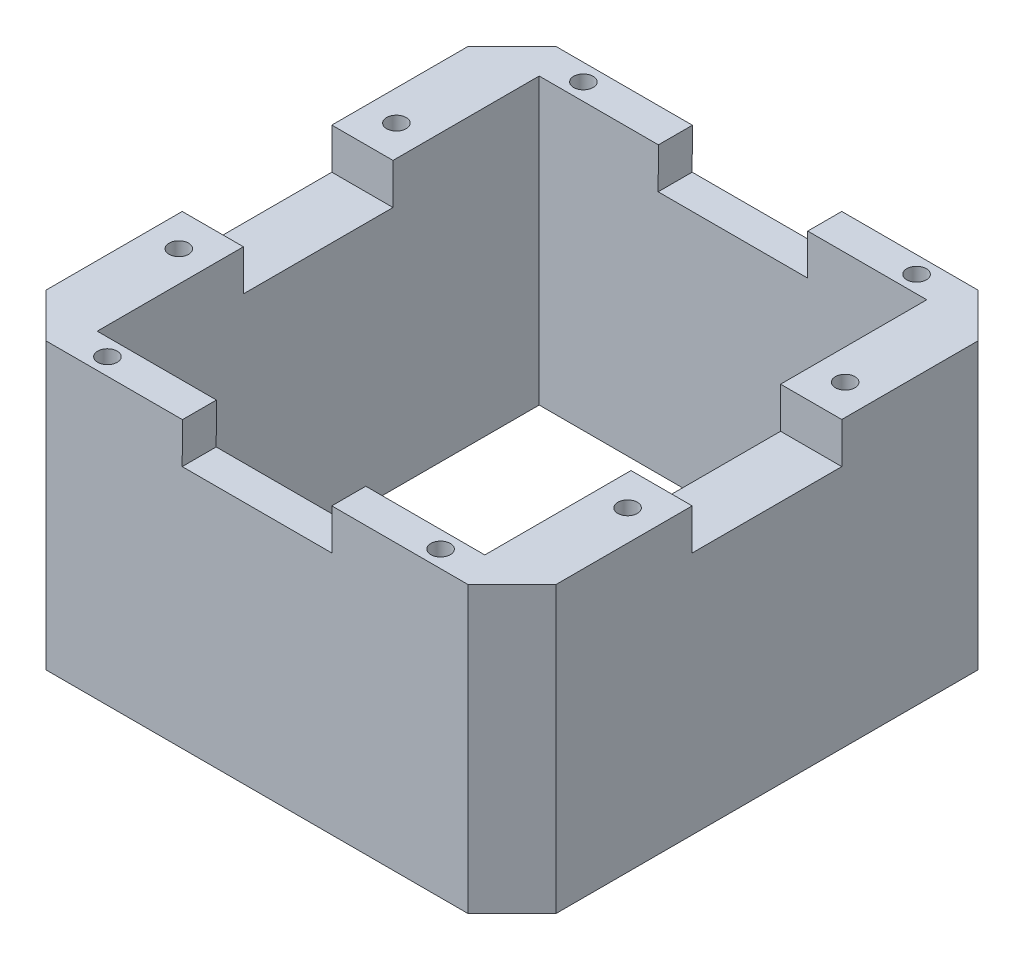
from build123d import *

# Parameters (mm, degrees)
SKETCH2_W                          = 75
SKETCH2_H                          = 75
SKETCH2_W_2                        = 57
SKETCH2_H_2                        = 65
BOSS_EXTRUDE1_DEPTH                = 41.91
CUT_EXTRUDE1_DEPTH                 = 92.91
SKETCH6_W                          = 22
SKETCH6_H                          = 6
CUT_EXTRUDE2_DEPTH                 = 92.91
CUT_EXTRUDE3_DEPTH                 = 92.91
CIRPATTERN1_COUNT                  = 4
TAP_DRILL_FOR_6_40_TAP1_AT_2_COUNT = 2
TAP_DRILL_FOR_6_40_TAP1_AT_2_PITCH = 32
CIRPATTERN2_COUNT                  = 2
TAP_DRILL_FOR_6_40_TAP2_AT_2_COUNT = 2
TAP_DRILL_FOR_6_40_TAP2_AT_2_PITCH = 49
CIRPATTERN4_COUNT                  = 2


with BuildPart() as part:
    # Sketch2 → Boss-Extrude1 (new body)
    with BuildSketch(Plane(origin=(0, 0, 0), x_dir=(1, 0, 0), z_dir=(0, 1, 0))):
        with Locations((-5.814990765, -18.037415397)):
            Rectangle(SKETCH2_W, SKETCH2_H)
        with Locations((-5.814990765, -18.037415397)):
            Rectangle(SKETCH2_W_2, SKETCH2_H_2, mode=Mode.SUBTRACT)
    extrude(amount=BOSS_EXTRUDE1_DEPTH)

    # Sketch4 → Cut-Extrude1 (cut)
    with BuildSketch(Plane(origin=(0, 0, -19.462584603), x_dir=(-1, 0, 0), z_dir=(0, 0, -1))):
        Polygon((16.782729205, 41.915021022), (-5.180449965, 41.91), (-5.180449965, 35.91), (16.819550035, 35.91), align=None)
    extrude(amount=-CUT_EXTRUDE1_DEPTH, mode=Mode.SUBTRACT)

    # Sketch6 → Cut-Extrude2 (cut)
    with BuildSketch(Plane.ZY.offset(43.314990765)):
        with Locations((18.037415397, 38.91)):
            Rectangle(SKETCH6_W, SKETCH6_H)
    extrude(amount=-CUT_EXTRUDE2_DEPTH, mode=Mode.SUBTRACT)

    # Sketch7 → Cut-Extrude3 (cut)
    with BuildSketch(Plane(origin=(0, 41.91, 0), x_dir=(1, 0, 0), z_dir=(0, 1, 0))):
        Polygon((31.685009235, 12.996800195), (25.219224828, 19.462584603), (31.685009235, 19.462584603), align=None)
    cut_extrude3 = extrude(amount=-CUT_EXTRUDE3_DEPTH, mode=Mode.SUBTRACT)

    # CirPattern1: Cut-Extrude3 ×4 about axis
    cirpattern1_axis = Axis((-5.814990765, 41.91, 18.037415397), (0, 1, 0))
    for i in range(1, CIRPATTERN1_COUNT):
        add(cut_extrude3.rotate(cirpattern1_axis, i * 360 / CIRPATTERN1_COUNT), mode=Mode.SUBTRACT)

    # Sketch18 → Tap Drill for _6-40 Tap1 (revolve, cut)
    with BuildSketch(Plane(origin=(-38.814990765, 41.91, 2.037415397), x_dir=(0, 0, 1), z_dir=(1, 0, 0))):
        Polygon((0, 0), (0, 20.862295074), (1.4351, 20), (1.4351, 0), align=None)
    tap_drill_for_6_40_tap1 = revolve(axis=Axis((-38.814990765, 48.26, 2.037415397), (0, -1, 0)), mode=Mode.SUBTRACT)

    # Tap Drill for _6-40 Tap1 at 2: Tap Drill for _6-40 Tap1 ×2
    with Locations(*[(0, 0, i * TAP_DRILL_FOR_6_40_TAP1_AT_2_PITCH) for i in range(1, TAP_DRILL_FOR_6_40_TAP1_AT_2_COUNT)]):
        add(tap_drill_for_6_40_tap1, mode=Mode.SUBTRACT)

    # CirPattern2: Tap Drill for _6-40 Tap1 ×2 about axis
    cirpattern2_axis = Axis((-5.814990765, 41.91, 18.037415397), (0, 1, 0))
    for i in range(1, CIRPATTERN2_COUNT):
        add(tap_drill_for_6_40_tap1.rotate(cirpattern2_axis, i * 360 / CIRPATTERN2_COUNT), mode=Mode.SUBTRACT)

    # CirPattern2 copy 1 sketch → CirPattern2 copy 1 (revolve, cut)
    with BuildSketch(Plane(origin=(27.185009235, 41.91, 2.037415397), x_dir=(0, 0, -1), z_dir=(-1, 0, 0))):
        Polygon((0, 0), (0, 20.862295074), (1.4351, 20), (1.4351, 0), align=None)
    revolve(axis=Axis((27.185009235, 48.26, 2.037415397), (0, -1, 0)), mode=Mode.SUBTRACT)

    # Sketch23 → Tap Drill for _6-40 Tap2 (revolve, cut)
    with BuildSketch(Plane(origin=(-30.314990765, 41.91, -16.962584603), x_dir=(0, 0, 1), z_dir=(1, 0, 0))):
        Polygon((0, 0), (0, 20.862295074), (1.4351, 20), (1.4351, 0), align=None)
    tap_drill_for_6_40_tap2 = revolve(axis=Axis((-30.314990765, 48.26, -16.962584603), (0, -1, 0)), mode=Mode.SUBTRACT)

    # Tap Drill for _6-40 Tap2 at 2: Tap Drill for _6-40 Tap2 ×2
    with Locations(*[(i * TAP_DRILL_FOR_6_40_TAP2_AT_2_PITCH, 0, 0) for i in range(1, TAP_DRILL_FOR_6_40_TAP2_AT_2_COUNT)]):
        add(tap_drill_for_6_40_tap2, mode=Mode.SUBTRACT)

    # CirPattern4: Tap Drill for _6-40 Tap2 ×2 about axis
    cirpattern4_axis = Axis((-5.814990765, 41.91, 18.037415397), (0, 1, 0))
    for i in range(1, CIRPATTERN4_COUNT):
        add(tap_drill_for_6_40_tap2.rotate(cirpattern4_axis, i * 360 / CIRPATTERN4_COUNT), mode=Mode.SUBTRACT)

    # CirPattern4 copy 1 sketch → CirPattern4 copy 1 (revolve, cut)
    with BuildSketch(Plane(origin=(-30.314990765, 41.91, 53.037415397), x_dir=(0, 0, -1), z_dir=(-1, 0, 0))):
        Polygon((0, 0), (0, 20.862295074), (1.4351, 20), (1.4351, 0), align=None)
    revolve(axis=Axis((-30.314990765, 48.26, 53.037415397), (0, -1, 0)), mode=Mode.SUBTRACT)


solid = part.part
